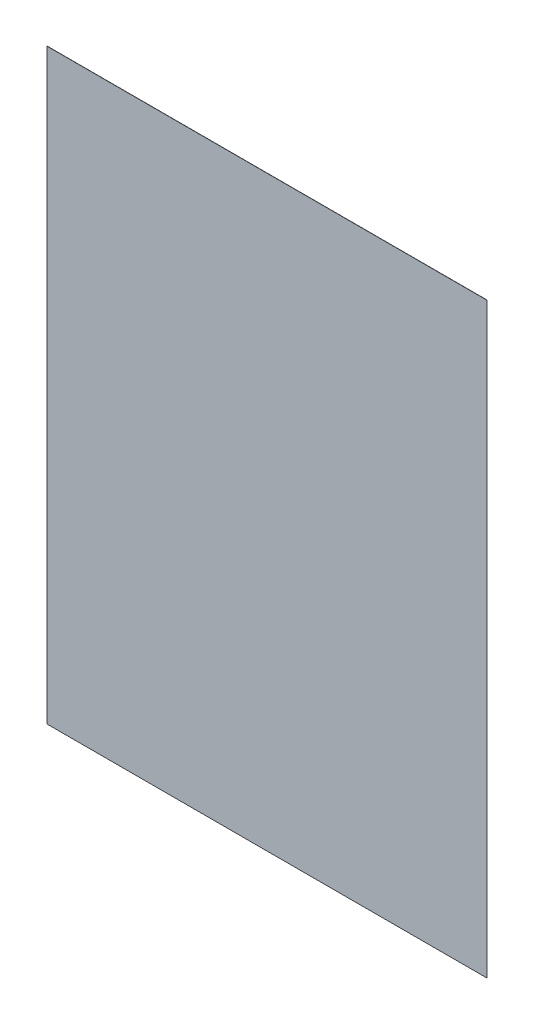
from build123d import *

# Parameters (mm, degrees)
SKETCH1_W  = 154
SKETCH1_H  = 205.5
BODY_DEPTH = 0.0686


with BuildPart() as part:
    # Sketch1 → Body (new body)
    with BuildSketch(Plane.XY):
        Rectangle(SKETCH1_W, SKETCH1_H)
    extrude(amount=BODY_DEPTH)


solid = part.part
